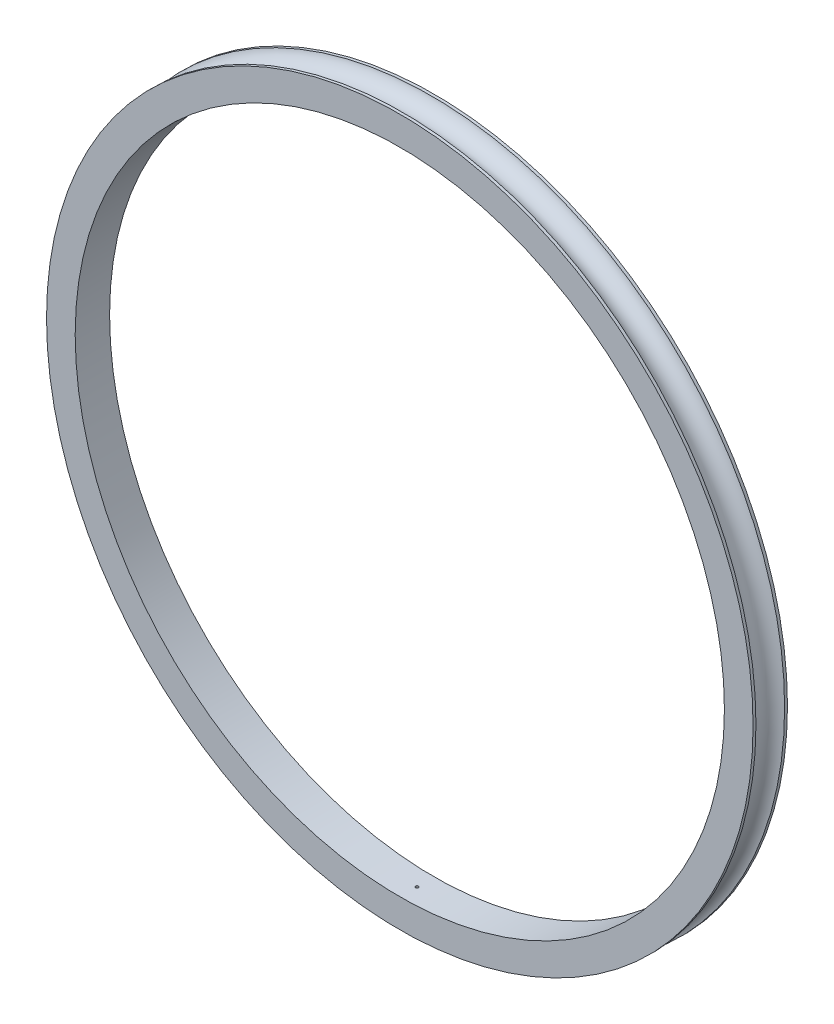
from build123d import *

# Parameters (mm, degrees)
SKETCH3_R          = 0.5
CUT_EXTRUDE1_DEPTH = 29
SKETCH4_R          = 0.5
CUT_EXTRUDE2_DEPTH = 11


with BuildPart() as part:
    # Sketch1 → Revolve1 (revolve)
    with BuildSketch(Plane(origin=(0, 0, 0), x_dir=(0, 0, -1), z_dir=(1, 0, 0))):
        with BuildLine():
            Line((0.5, 113.24716621), (6, 113.24716621))
            Line((6, 113.24716621), (6, 123.24716621))
            Line((6, 123.24716621), (5, 123.24716621))
            ThreePointArc((5, 123.24716621), (0, 119.24716621), (-5, 123.24716621))
            Line((-5, 123.24716621), (-6, 123.24716621))
            Line((-6, 123.24716621), (-6, 113.24716621))
            Line((-6, 113.24716621), (-0.5, 113.24716621))
            Line((-0.5, 113.24716621), (0.5, 113.24716621))
        make_face()
    revolve(axis=Axis((0, 0, 80.785821763), (0, 0, -1)))

    # Sketch3 → Cut-Extrude1 (cut)
    with BuildSketch(Plane(origin=(0, 115.24716621, 0), x_dir=(-1, 0, 0), z_dir=(0, -1, 0))):
        Circle(SKETCH3_R)
    extrude(amount=CUT_EXTRUDE1_DEPTH, mode=Mode.SUBTRACT)

    # Sketch4 → Cut-Extrude2 (cut)
    with BuildSketch(Plane(origin=(0, -115.24716621, 0), x_dir=(1, 0, 0), z_dir=(0, 1, 0))):
        Circle(SKETCH4_R)
    extrude(amount=CUT_EXTRUDE2_DEPTH, mode=Mode.SUBTRACT)


solid = part.part
